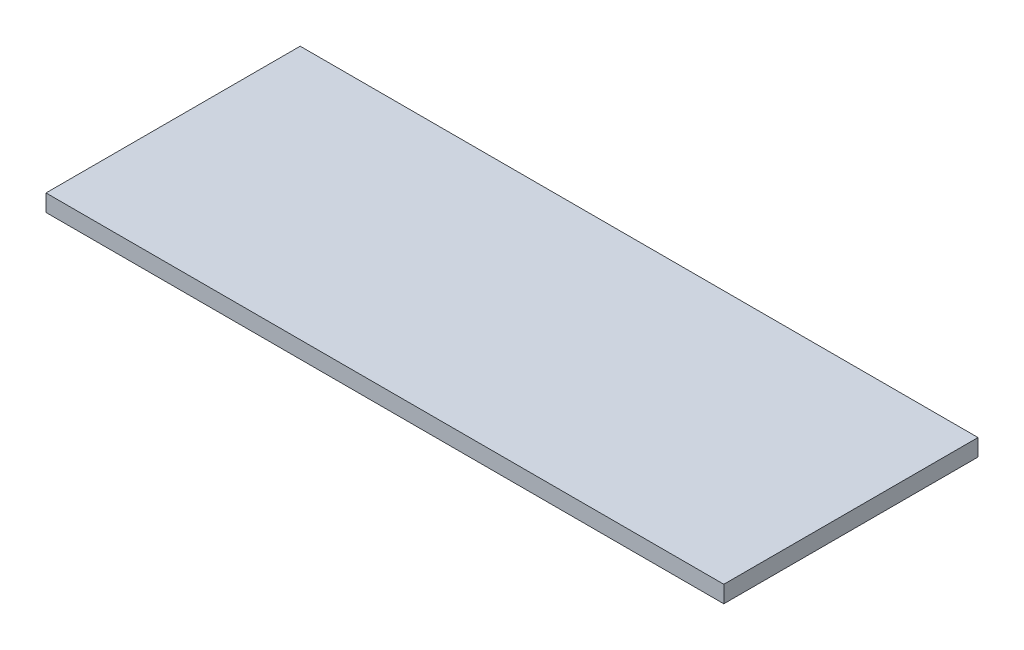
from build123d import *

# Parameters (mm, degrees)
SKETCH1_W           = 8000
SKETCH1_H           = 3000
BOSS_EXTRUDE1_DEPTH = 100


with BuildPart() as part:
    # Sketch1 → Boss-Extrude1 (new body, symmetric)
    with BuildSketch(Plane(origin=(0, 0, 0), x_dir=(1, 0, 0), z_dir=(0, 1, 0))):
        Rectangle(SKETCH1_W, SKETCH1_H)
    extrude(amount=BOSS_EXTRUDE1_DEPTH, both=True)


solid = part.part
